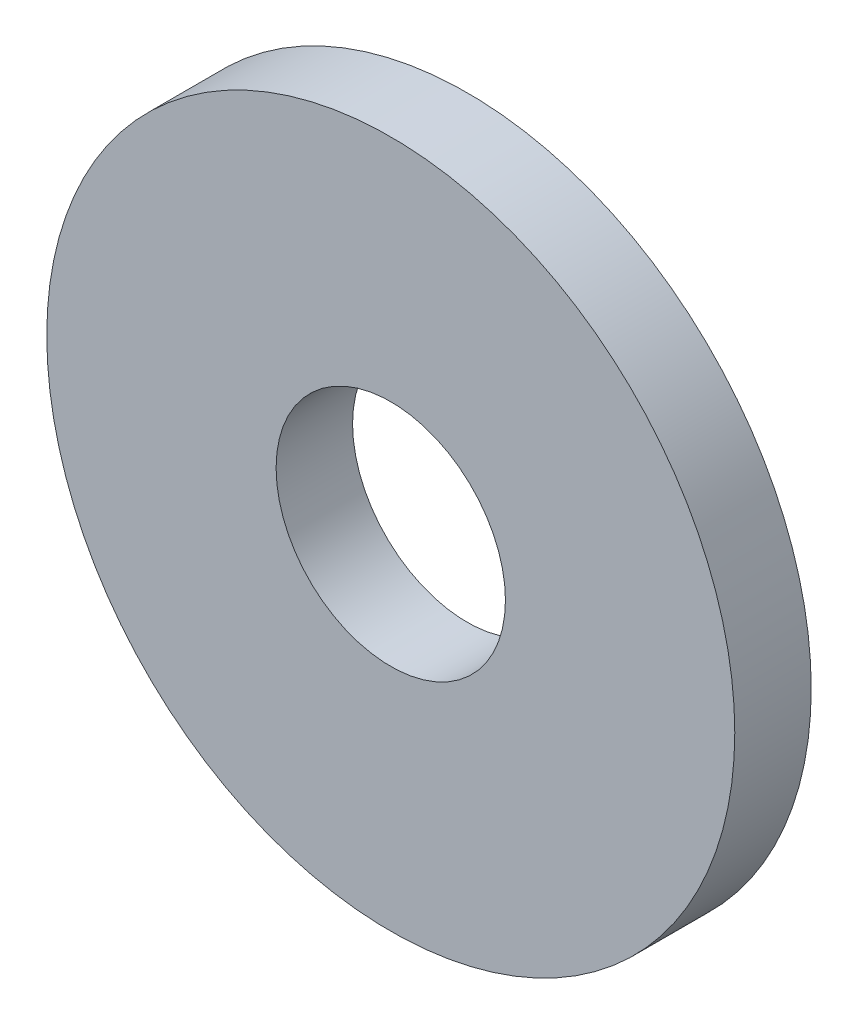
from build123d import *

# Parameters (mm, degrees)
SKETCH1_R           = 2.25
SKETCH1_R_2         = 0.75
BOSS_EXTRUDE1_DEPTH = 0.5


with BuildPart() as part:
    # Sketch1 → Boss-Extrude1 (new body)
    with BuildSketch(Plane.XY):
        Circle(SKETCH1_R)
        Circle(SKETCH1_R_2, mode=Mode.SUBTRACT)
    extrude(amount=BOSS_EXTRUDE1_DEPTH)


solid = part.part
